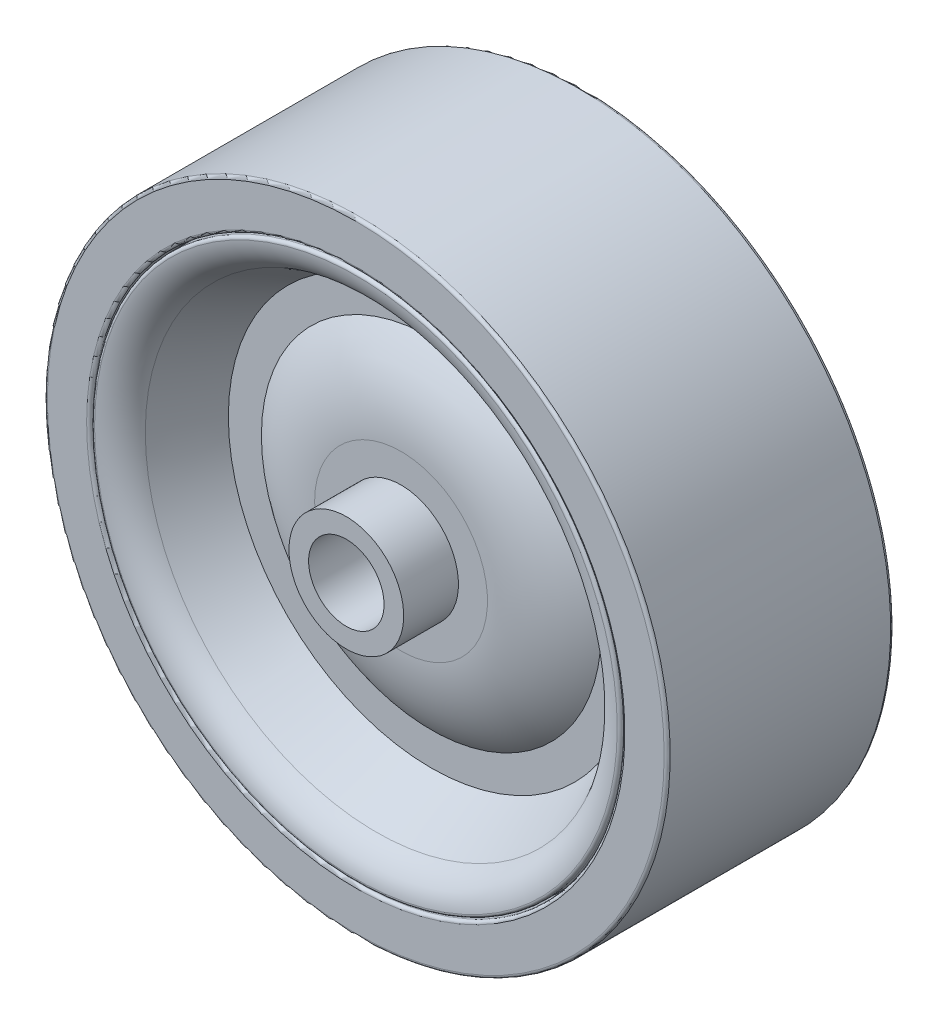
from build123d import *

# Parameters (mm, degrees)
FILLET1_R = 0.254


with BuildPart() as part:
    # Sketch1 → Revolve1 (revolve)
    with BuildSketch(Plane(origin=(0, 0, 0), x_dir=(0, 0, -1), z_dir=(1, 0, 0)), mode=Mode.PRIVATE) as revolve1_sk:
        with BuildLine():
            Line((0, 26.19375), (9.525, 26.19375))
            Line((9.525, 26.19375), (9.525, 22.38375))
            Line((9.525, 22.38375), (6.985, 22.38375))
            Line((6.985, 22.38375), (6.985, 22.25675))
            Line((6.985, 22.25675), (9.525, 22.25675))
            ThreePointArc((9.525, 22.25675), (9.058555387, 20.600141201), (7.796273881, 19.430282795))
            Line((7.796273881, 19.430282795), (3.175, 17.065625))
            Line((3.175, 17.065625), (3.175, 14.2875))
            ThreePointArc((3.175, 14.2875), (5.060465212, 11.001230365), (5.715, 7.269457141))
            Line((5.715, 7.269457141), (5.715, 4.826))
            Line((5.715, 4.826), (10.31875, 4.826))
            Line((10.31875, 4.826), (10.31875, 3.175))
            Line((10.31875, 3.175), (0, 3.175))
            Line((0, 3.175), (0, 26.19375))
        make_face()
    revolve(revolve1_sk.sketch.rotate(Axis((0, 0, -10.31875), (0, 0, 1)), 90), axis=Axis((0, 0, -10.31875), (0, 0, 1)))

    # Fillet1
    fillet1_edges = [part.edges().sort_by_distance(p)[0] for p in [
        (22.25675, 0, -9.525),
        (22.38375, 0, -9.525),
        (26.19375, 0, -9.525),
    ]]
    fillet(fillet1_edges, radius=FILLET1_R)

    # Mirror1: part across plane


with BuildPart() as part_1:
    add(part.part)
    add(part.part.mirror(Plane.XY))


solid = part_1.part
